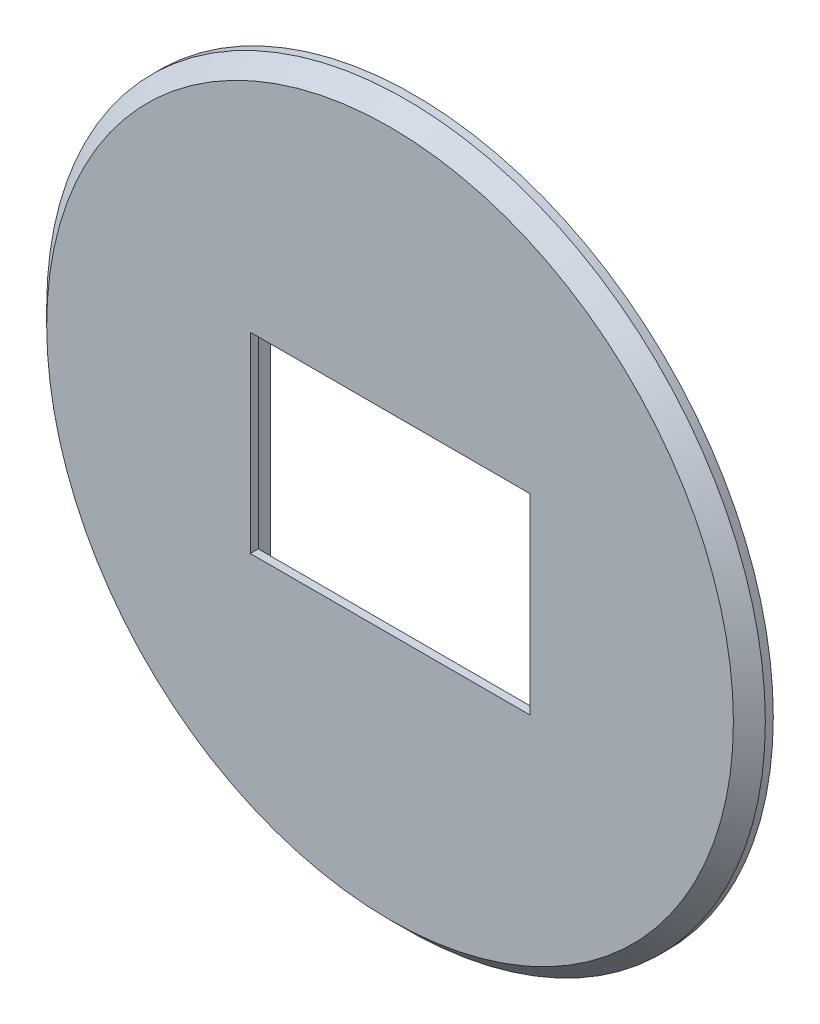
from build123d import *

# Parameters (mm, degrees)
SKETCH1_R           = 45
BOSS_EXTRUDE1_DEPTH = 3
SKETCH2_W           = 35
SKETCH2_H           = 24
CUT_EXTRUDE1_DEPTH  = 3
CHAMFER1_SIZE       = 2
SKETCH3_W           = 36
SKETCH3_H           = 34
CUT_EXTRUDE2_DEPTH  = 2


with BuildPart() as part:
    # Sketch1 → Boss-Extrude1 (new body)
    with BuildSketch(Plane.XY):
        Circle(SKETCH1_R)
    extrude(amount=BOSS_EXTRUDE1_DEPTH)

    # Sketch2 → Cut-Extrude1 (cut)
    with BuildSketch(Plane.XY.offset(3)):
        Rectangle(SKETCH2_W, SKETCH2_H)
    extrude(amount=-CUT_EXTRUDE1_DEPTH, mode=Mode.SUBTRACT)

    # Chamfer1
    chamfer1_edges = [part.edges().sort_by_distance(p)[0] for p in [
        (-45, 0, 3),
    ]]
    chamfer(chamfer1_edges, length=CHAMFER1_SIZE)

    # Sketch3 → Cut-Extrude2 (cut)
    with BuildSketch(Plane(origin=(0, 0, 0), x_dir=(-1, 0, 0), z_dir=(0, 0, -1))):
        Rectangle(SKETCH3_W, SKETCH3_H)
    extrude(amount=-CUT_EXTRUDE2_DEPTH, mode=Mode.SUBTRACT)


solid = part.part
